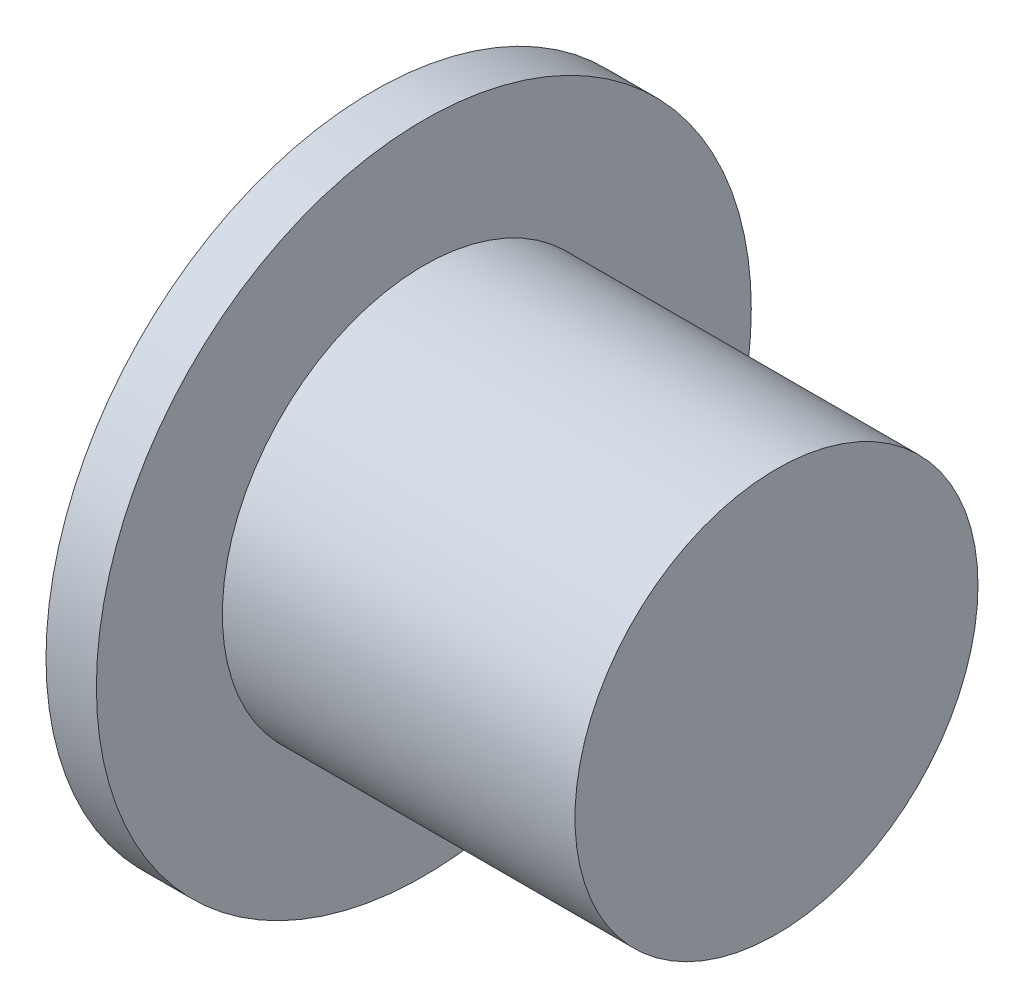
from build123d import *

# Parameters (mm, degrees)
SKETCH2_R           = 4
BOSS_EXTRUDE1_DEPTH = 7
SKETCH3_R           = 6.5
BOSS_EXTRUDE2_DEPTH = 1


with BuildPart() as part:
    # Sketch2 → Boss-Extrude1 (new body)
    with BuildSketch(Plane(origin=(0, 0, 0), x_dir=(0, 0, -1), z_dir=(1, 0, 0))):
        Circle(SKETCH2_R)
    extrude(amount=-BOSS_EXTRUDE1_DEPTH)

    # Sketch3 → Boss-Extrude2 (add)
    with BuildSketch(Plane.ZY.offset(7)):
        Circle(SKETCH3_R)
    extrude(amount=BOSS_EXTRUDE2_DEPTH)


solid = part.part
